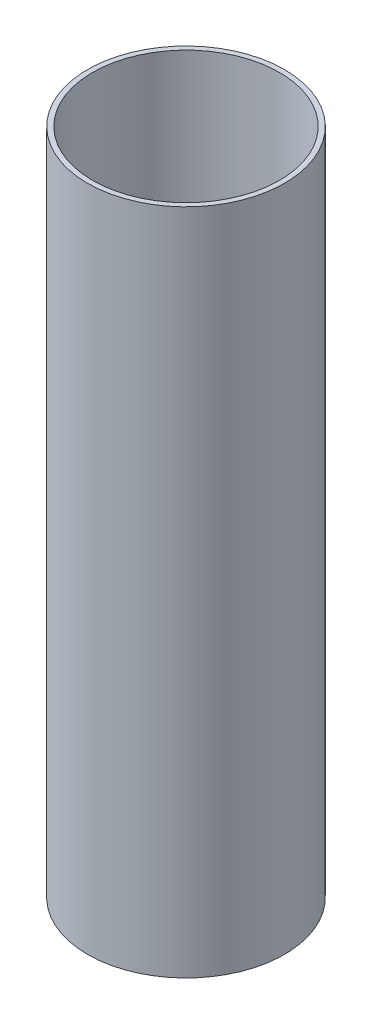
from build123d import *

# Parameters (mm, degrees)
SKETCH1_R           = 93.6625
SKETCH1_R_2         = 88.9
BOSS_EXTRUDE1_DEPTH = 317.5


with BuildPart() as part:
    # Sketch1 → Boss-Extrude1 (new body, symmetric)
    with BuildSketch(Plane(origin=(0, 0, 0), x_dir=(1, 0, 0), z_dir=(0, 1, 0))):
        Circle(SKETCH1_R)
        Circle(SKETCH1_R_2, mode=Mode.SUBTRACT)
    extrude(amount=BOSS_EXTRUDE1_DEPTH, both=True)


solid = part.part
